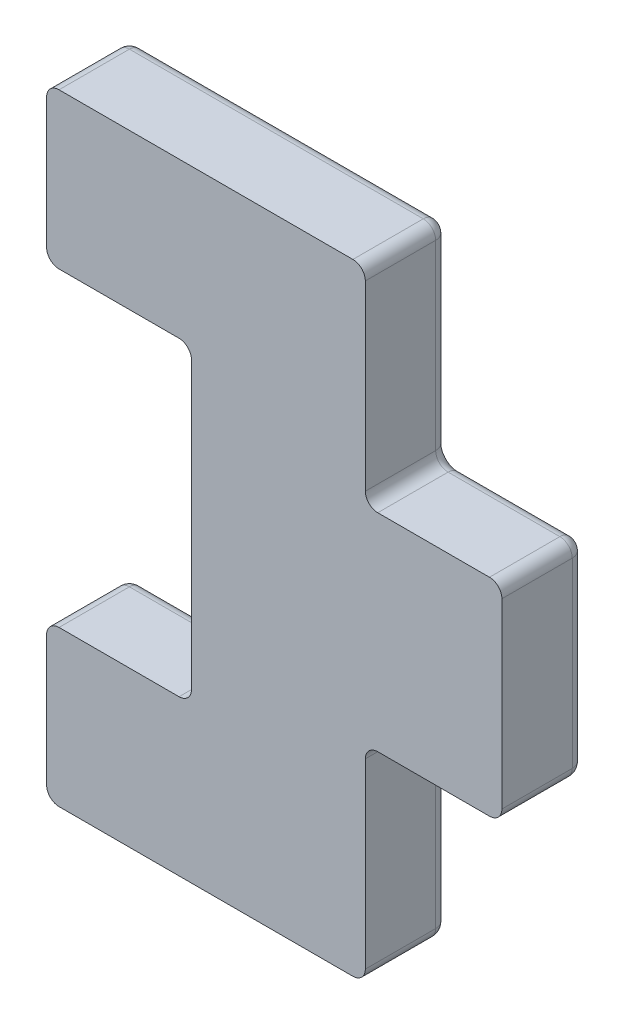
from build123d import *

# Parameters (mm, degrees)
GRUNDK_RPER_DEPTH = 2
VERRUNDUNG1_R     = 0.3
VERRUNDUNG2_R     = 0.3


with BuildPart() as part:
    # Skizze1 → Grundkörper (new body)
    with BuildSketch(Plane.XY):
        Polygon((0, -3.75), (0, 3.75), (-3.5, 3.75), (-3.5, 7.5), (4.2, 7.5), (4.2, 2.5), (7.5, 2.5), (7.5, -2.5), (4.2, -2.5), (4.2, -7.5), (-3.5, -7.5), (-3.5, -3.75), align=None)
    extrude(amount=GRUNDK_RPER_DEPTH)

    # Verrundung1
    verrundung1_edges = [part.edges().sort_by_distance(p)[0] for p in [
        (4.2, 7.5, 1),
        (4.2, 2.5, 1),
        (7.5, 2.5, 1),
        (7.5, -2.5, 1),
        (4.2, -2.5, 1),
        (4.2, -7.5, 1),
        (-3.5, -7.5, 1),
        (-3.5, -3.75, 1),
        (0, -3.75, 1),
        (0, 3.75, 1),
        (-3.5, 3.75, 1),
        (-3.5, 7.5, 1),
    ]]
    fillet(verrundung1_edges, radius=VERRUNDUNG1_R)

    # Verrundung2
    verrundung2_edges = [part.edges().sort_by_distance(p)[0] for p in [
        (0.35, 7.5, 0),
        (4.2, 5, 0),
        (5.85, 2.5, 0),
        (7.5, 0, 0),
        (5.85, -2.5, 0),
        (4.2, -5, 0),
        (0.35, -7.5, 0),
        (-3.5, -5.625, 0),
        (-1.75, -3.75, 0),
        (0, 0, 0),
        (-1.75, 3.75, 0),
        (-3.5, 5.625, 0),
        (7.412132034, -2.412132034, 0),
        (4.112132034, -7.412132034, 0),
        (-3.412132034, -7.412132034, 0),
        (-3.412132034, -3.837867966, 0),
        (-3.412132034, 3.837867966, 0),
        (-3.412132034, 7.412132034, 0),
        (7.412132034, 2.412132034, 0),
        (4.112132034, 7.412132034, 0),
        (4.287867966, 2.587867966, 0),
        (-0.087867966, 3.662132034, 0),
        (-0.087867966, -3.662132034, 0),
        (4.287867966, -2.587867966, 0),
    ]]
    fillet(verrundung2_edges, radius=VERRUNDUNG2_R)


solid = part.part
